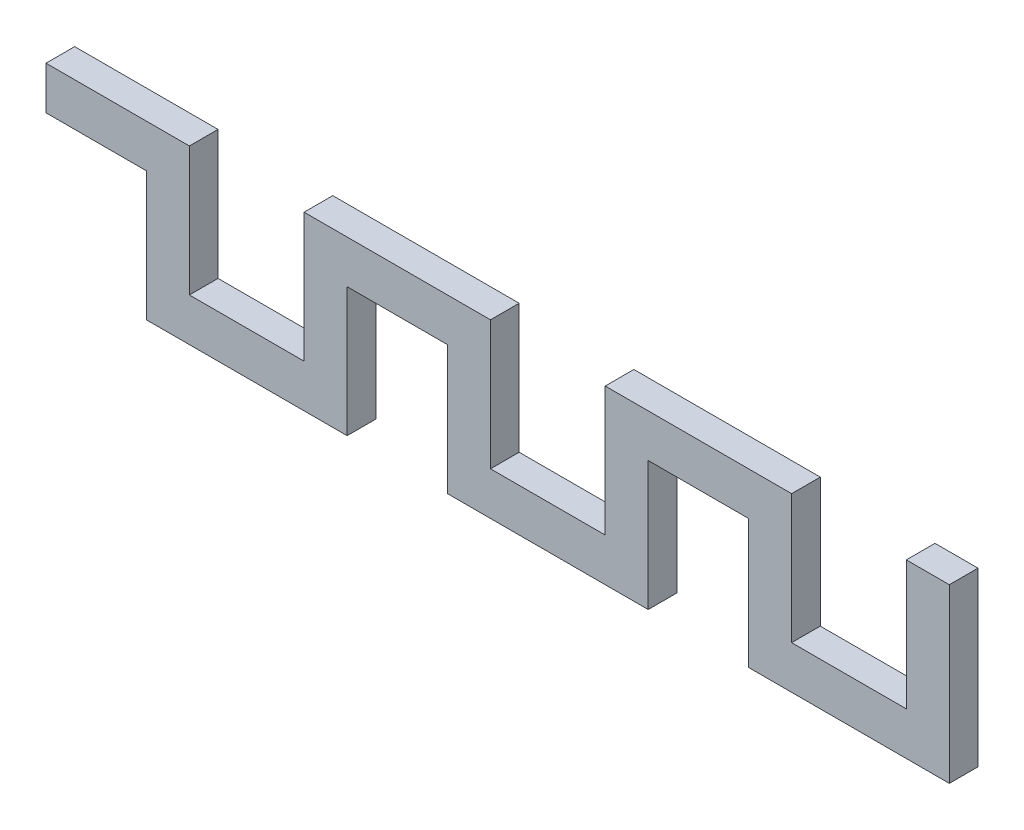
from build123d import *

# Parameters (mm, degrees)
EXTRUDE_1_DEPTH = 4


with BuildPart() as part:
    # 草图1 → 凸台-拉伸1 (new body)
    with BuildSketch(Plane.XY):
        Polygon((0, 0), (20, 0), (20, -18), (36, -18), (36, 0), (62, 0), (62, -18), (78, -18), (78, 0), (104, 0), (104, -18), (120, -18), (120, 0), (126, 0), (126, -6), (126, -24), (98, -24), (98, -6), (84, -6), (84, -24), (56, -24), (56, -6), (42, -6), (42, -24), (14, -24), (14, -6), (0, -6), align=None)
    extrude(amount=EXTRUDE_1_DEPTH)


solid = part.part
